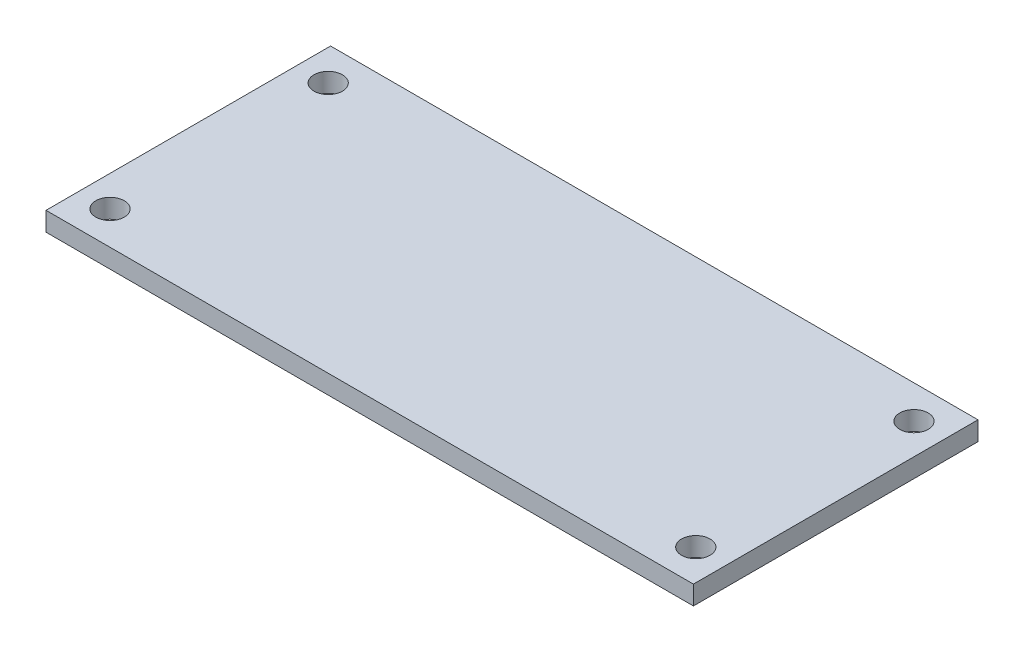
from build123d import *

# Parameters (mm, degrees)
SKETCH1_W           = 68.25
SKETCH1_H           = 30
SKETCH1_R           = 1.5
BOSS_EXTRUDE1_DEPTH = 2


with BuildPart() as part:
    # Sketch1 → Boss-Extrude1 (new body)
    with BuildSketch(Plane(origin=(0, 0, 0), x_dir=(1, 0, 0), z_dir=(0, 1, 0))):
        with Locations((34.125, 15)):
            Rectangle(SKETCH1_W, SKETCH1_H)
        with Locations((3.25, 3.5)):
            Circle(SKETCH1_R, mode=Mode.SUBTRACT)
        with Locations((65, 26.5)):
            Circle(SKETCH1_R, mode=Mode.SUBTRACT)
        with Locations((65, 3.5)):
            Circle(SKETCH1_R, mode=Mode.SUBTRACT)
        with Locations((3.25, 26.5)):
            Circle(SKETCH1_R, mode=Mode.SUBTRACT)
    extrude(amount=BOSS_EXTRUDE1_DEPTH)


solid = part.part
